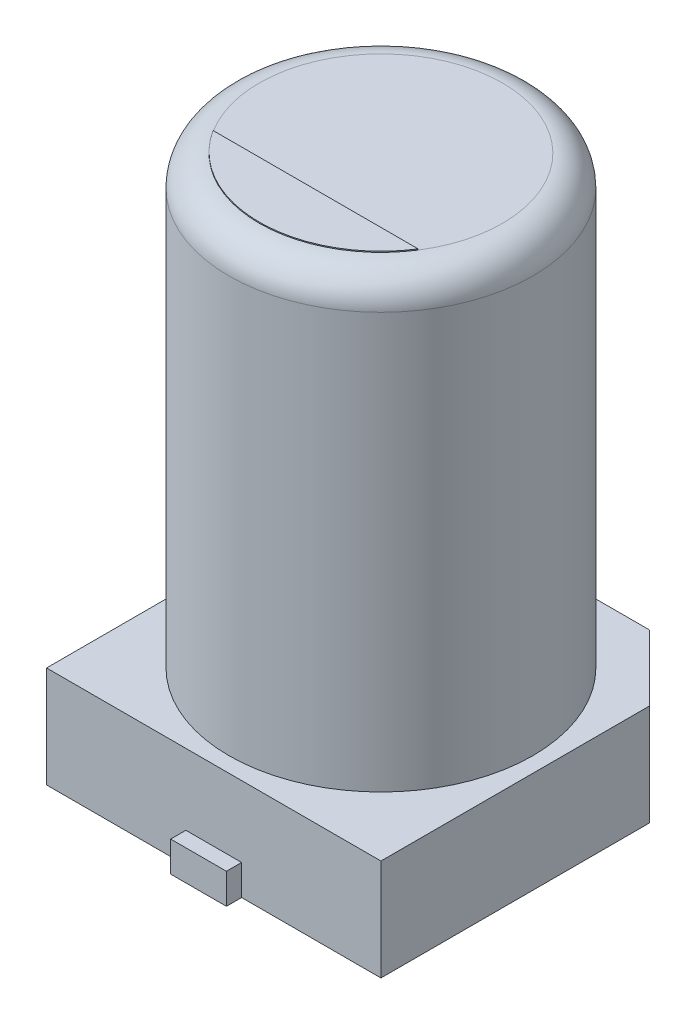
from build123d import *

# Parameters (mm, degrees)
BOSS_EXTRUDE1_DEPTH = 1
SKETCH3_R           = 1.5
BOSS_EXTRUDE2_DEPTH = 5.4
FILLET1_R           = 0.3
SKETCH4_W           = 0.55
SKETCH4_H           = 1.5
BOSS_EXTRUDE3_DEPTH = 0.3
BOSS_EXTRUDE4_DEPTH = 0.01


with BuildPart() as part:
    # Sketch2 → Boss-Extrude1 (new body)
    with BuildSketch(Plane(origin=(0, 0, 0), x_dir=(1, 0, 0), z_dir=(0, 1, 0))):
        Polygon((1.65, -1.65), (-1.65, -1.65), (-1.65, 1), (-1, 1.65), (1, 1.65), (1.65, 1), align=None)
    extrude(amount=BOSS_EXTRUDE1_DEPTH)

    # Sketch3 → Boss-Extrude2 (add)
    with BuildSketch(Plane(origin=(0, 0, 0), x_dir=(1, 0, 0), z_dir=(0, 1, 0))):
        Circle(SKETCH3_R)
    extrude(amount=BOSS_EXTRUDE2_DEPTH)

    # Fillet1
    fillet1_edges = [part.edges().sort_by_distance(p)[0] for p in [
        (-1.5, 5.4, 0),
    ]]
    fillet(fillet1_edges, radius=FILLET1_R)

    # Sketch4 → Boss-Extrude3 (add)
    with BuildSketch(Plane(origin=(0, 0, 0), x_dir=(1, 0, 0), z_dir=(0, 1, 0))):
        with Locations((0, 1.05)):
            Rectangle(SKETCH4_W, SKETCH4_H)
        with Locations((0, -1.05)):
            Rectangle(SKETCH4_W, SKETCH4_H)
    extrude(amount=BOSS_EXTRUDE3_DEPTH)

    # Sketch5 → Boss-Extrude4 (add)
    with BuildSketch(Plane(origin=(0, 5.4, 0), x_dir=(1, 0, 0), z_dir=(0, 1, 0))):
        with BuildLine():
            Line((1.012005665, -0.644860089), (-1.012005665, -0.644860089))
            ThreePointArc((-1.012005665, -0.644860089), (0, -1.2), (1.012005665, -0.644860089))
        make_face()
    extrude(amount=BOSS_EXTRUDE4_DEPTH)


solid = part.part
